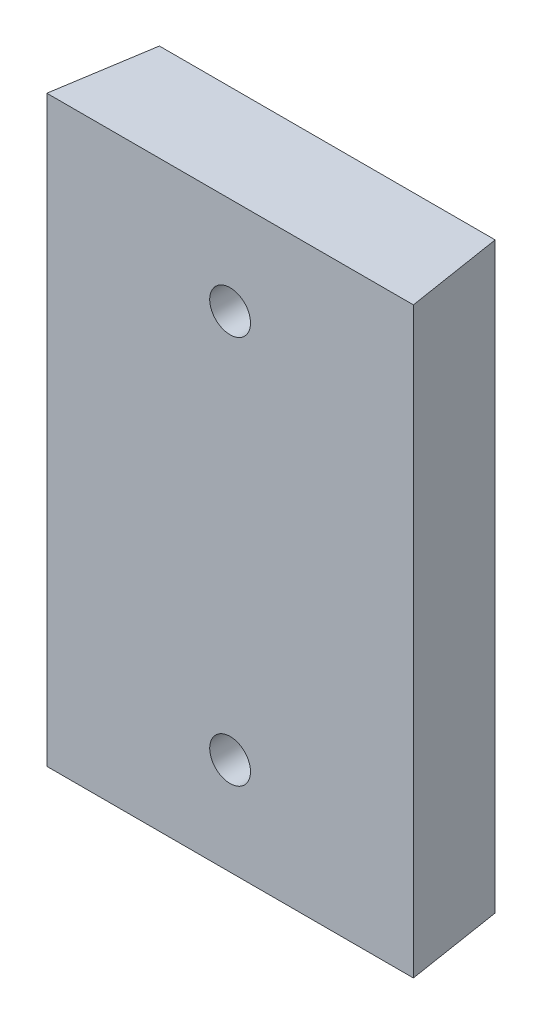
from build123d import *

# Parameters (mm, degrees)
IZIM1_W                     = 43.801650212
IZIM1_H                     = 60
IZIM1_R                     = 2.1
Y_KSEKLIK_EKSTR_ZYON1_DEPTH = 10
KES_EKSTR_ZYON1_DEPTH       = 81


with BuildPart() as part:
    # Çizim1 → Yükseklik-Ekstrüzyon1 (new body)
    with BuildSketch(Plane.XY):
        Rectangle(IZIM1_W, IZIM1_H)
        with Locations((0, -20)):
            Circle(IZIM1_R, mode=Mode.SUBTRACT)
        with Locations((0, 20)):
            Circle(IZIM1_R, mode=Mode.SUBTRACT)
    extrude(amount=Y_KSEKLIK_EKSTR_ZYON1_DEPTH)

    # Çizim2 → Kes-Ekstrüzyon1 (cut)
    with BuildSketch(Plane(origin=(0, 30, 0), x_dir=(1, 0, 0), z_dir=(0, 1, 0))):
        Polygon((-15.608960187, 10.547911998), (-27.517863297, 10.547911998), (-27.517863297, -12.148896601), (-18.937760084, -10.469303395), align=None)
        Polygon((27.517863297, -12.148896601), (18.937760084, -10.469303395), (15.608960187, 10.547911998), (27.517863297, 10.547911998), align=None)
    extrude(amount=-KES_EKSTR_ZYON1_DEPTH, mode=Mode.SUBTRACT)


solid = part.part
